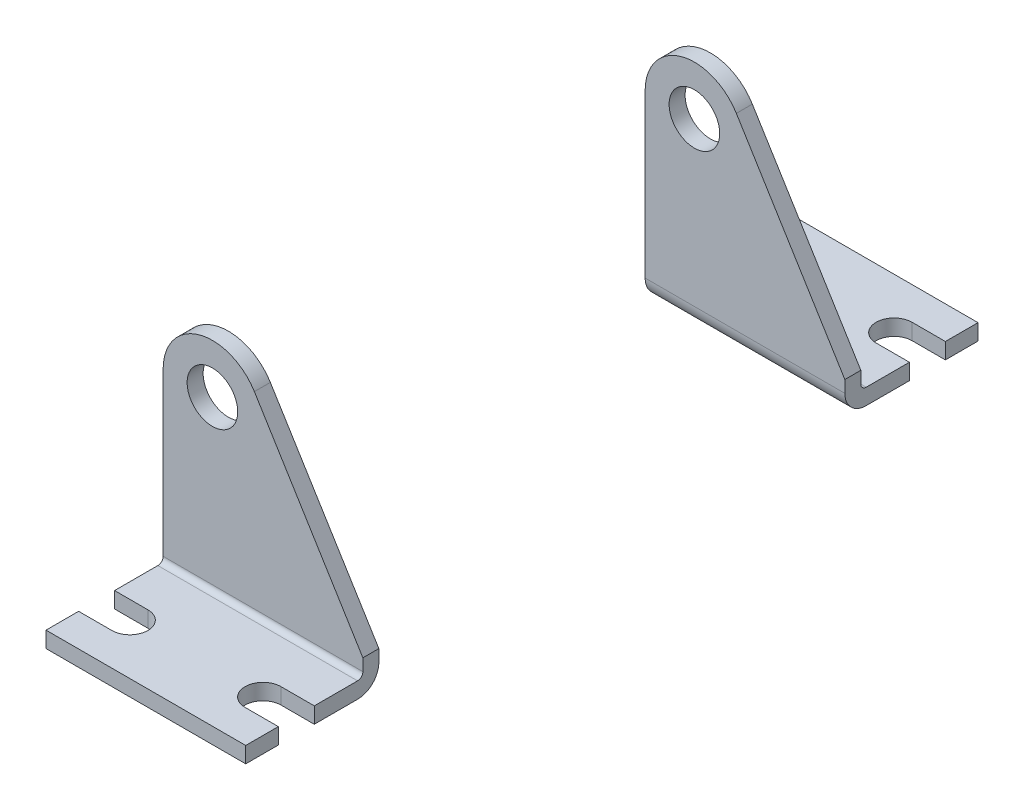
from build123d import *

# Parameters (mm, degrees)
SKETCH3_R           = 4.826
BOSS_EXTRUDE1_DEPTH = 3.048
SKETCH4_W           = 38.1
SKETCH4_H           = 3.048
BOSS_EXTRUDE2_DEPTH = 22.352
CUT_EXTRUDE1_DEPTH  = 4.048
FILLET1_R           = 1.016
FILLET2_R           = 4.064


with BuildPart() as part:
    # Sketch3 → Boss-Extrude1 (new body)
    with BuildSketch(Plane.XY):
        with BuildLine():
            Line((-9.398, 0), (-9.398, -35.052))
            Line((-9.398, -35.052), (28.702, -35.052))
            Line((28.702, -35.052), (28.702, -28.702))
            Line((28.702, -28.702), (8.003429206, 4.926207967))
            ThreePointArc((8.003429206, 4.926207967), (-2.559900029, 9.042638765), (-9.398, 0))
        make_face()
        Circle(SKETCH3_R, mode=Mode.SUBTRACT)
    extrude(amount=BOSS_EXTRUDE1_DEPTH)

    # Sketch4 → Boss-Extrude2 (add)
    with BuildSketch(Plane.XY.offset(3.048)):
        with Locations((9.652, -33.528)):
            Rectangle(SKETCH4_W, SKETCH4_H)
    extrude(amount=BOSS_EXTRUDE2_DEPTH)

    # Sketch5 → Cut-Extrude1 (cut, through all)
    with BuildSketch(Plane(origin=(0, -32.004, 0), x_dir=(1, 0, 0), z_dir=(0, 1, 0))):
        with BuildLine():
            Line((-3.048, -19.177), (-9.398, -19.177))
            Line((-9.398, -19.177), (-9.398, -12.319))
            Line((-9.398, -12.319), (-3.048, -12.319))
            ThreePointArc((-3.048, -12.319), (0.381, -15.748), (-3.048, -19.177))
        make_face()
        with BuildLine():
            Line((22.352, -12.319), (28.702, -12.319))
            Line((28.702, -12.319), (28.702, -19.177))
            Line((28.702, -19.177), (22.352, -19.177))
            ThreePointArc((22.352, -19.177), (18.923, -15.748), (22.352, -12.319))
        make_face()
    extrude(amount=-CUT_EXTRUDE1_DEPTH, mode=Mode.SUBTRACT)

    # Fillet1
    fillet1_edges = [part.edges().sort_by_distance(p)[0] for p in [
        (9.652, -32.004, 3.048),
    ]]
    fillet(fillet1_edges, radius=FILLET1_R)

    # Fillet2
    fillet2_edges = [part.edges().sort_by_distance(p)[0] for p in [
        (9.652, -35.052, 0),
    ]]
    fillet(fillet2_edges, radius=FILLET2_R)


with BuildPart() as body_2:
    # Mirror2: mirrored copy
    add(part.part.mirror(Plane.XY.offset(-44.45)))


solid = Compound([part.part, body_2.part])
